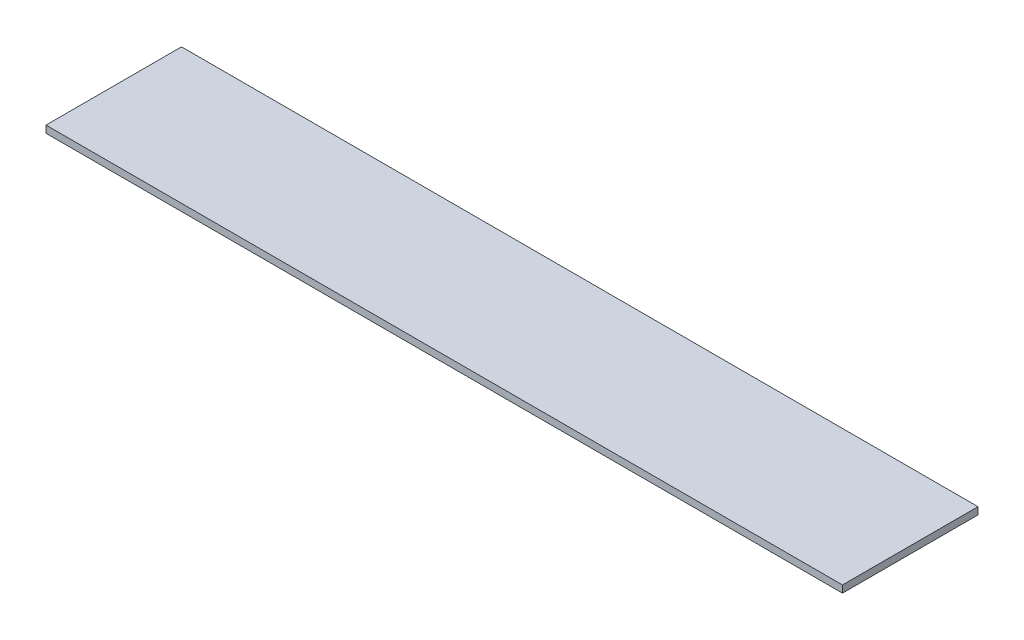
from build123d import *

# Parameters (mm, degrees)
SKETCH1_W      = 335
SKETCH1_H      = 57
EXTRUDE1_DEPTH = 3


with BuildPart() as part:
    # Sketch1 → Extrude1 (new body)
    with BuildSketch(Plane(origin=(0, 0, 0), x_dir=(1, 0, 0), z_dir=(0, 1, 0))):
        Rectangle(SKETCH1_W, SKETCH1_H)
    extrude(amount=EXTRUDE1_DEPTH)


solid = part.part
